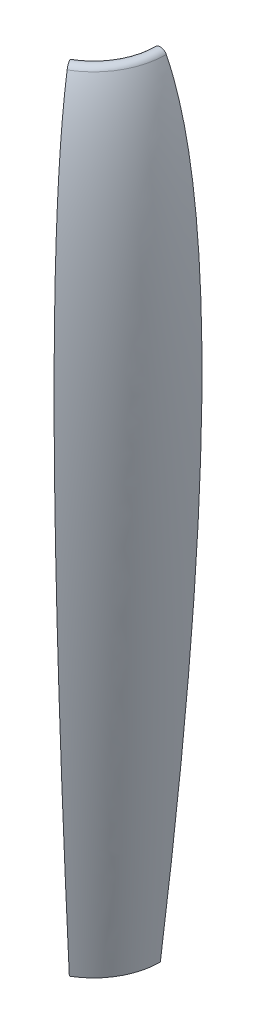
from build123d import *

# Parameters (mm, degrees)
MAIN_EXTRUDE_ANGLE = 60
SKETCH4_R          = 3.175
SPAR_HOLES_1_DEPTH = 12.7
SKETCH5_R          = 3.175
SPAR_HOLES_2_DEPTH = 12.7


with BuildPart() as part:
    # Sketch3 → Main extrude (revolve)
    with BuildSketch(Plane.XY):
        with BuildLine():
            ThreePointArc((-2.267771894, 148.348367024), (0, 149.744334404), (2.267771894, 148.348367024))
            add(Edge.make_bspline(
                [(2.267771894, 148.348367024), (30.572440123, 92.24111101), (0, -152.4)],
                knots=[0, 0, 0, 1, 1, 1], degree=2))
            add(Edge.make_bspline(
                [(-2.267771894, 148.348367024), (-30.572440123, 92.24111101), (0, -152.4)],
                knots=[0, 0, 0, 1, 1, 1], degree=2))
        make_face()
        with BuildLine():
            Line((3.81, 57.15), (3.81, -6.35))
            ThreePointArc((3.81, -6.35), (0, -10.16), (-3.81, -6.35))
            Line((-3.81, -6.35), (-3.81, 57.15))
            ThreePointArc((-3.81, 57.15), (0, 60.96), (3.81, 57.15))
        make_face(mode=Mode.SUBTRACT)
    revolve(axis=Axis((-25.4, 132.199806754, 0), (0, -1, 0)), revolution_arc=MAIN_EXTRUDE_ANGLE)

    # Sketch4 → Spar holes 1 (cut)
    with BuildSketch(Plane(origin=(-19.05, 0, 10.998522628), x_dir=(0.5, 0, 0.866025404), z_dir=(-0.866025404, 0, 0.5))):
        with Locations((12.7, 82.55)):
            Circle(SKETCH4_R)
        with Locations((12.7, -31.75)):
            Circle(SKETCH4_R)
    extrude(amount=-SPAR_HOLES_1_DEPTH, mode=Mode.SUBTRACT)

    # Sketch5 → Spar holes 2 (cut)
    with BuildSketch(Plane(origin=(0, 0, 0), x_dir=(-1, 0, 0), z_dir=(0, 0, -1))):
        with Locations((0, 82.55)):
            Circle(SKETCH5_R)
        with Locations((0, -31.75)):
            Circle(SKETCH5_R)
    extrude(amount=-SPAR_HOLES_2_DEPTH, mode=Mode.SUBTRACT)


solid = part.part
